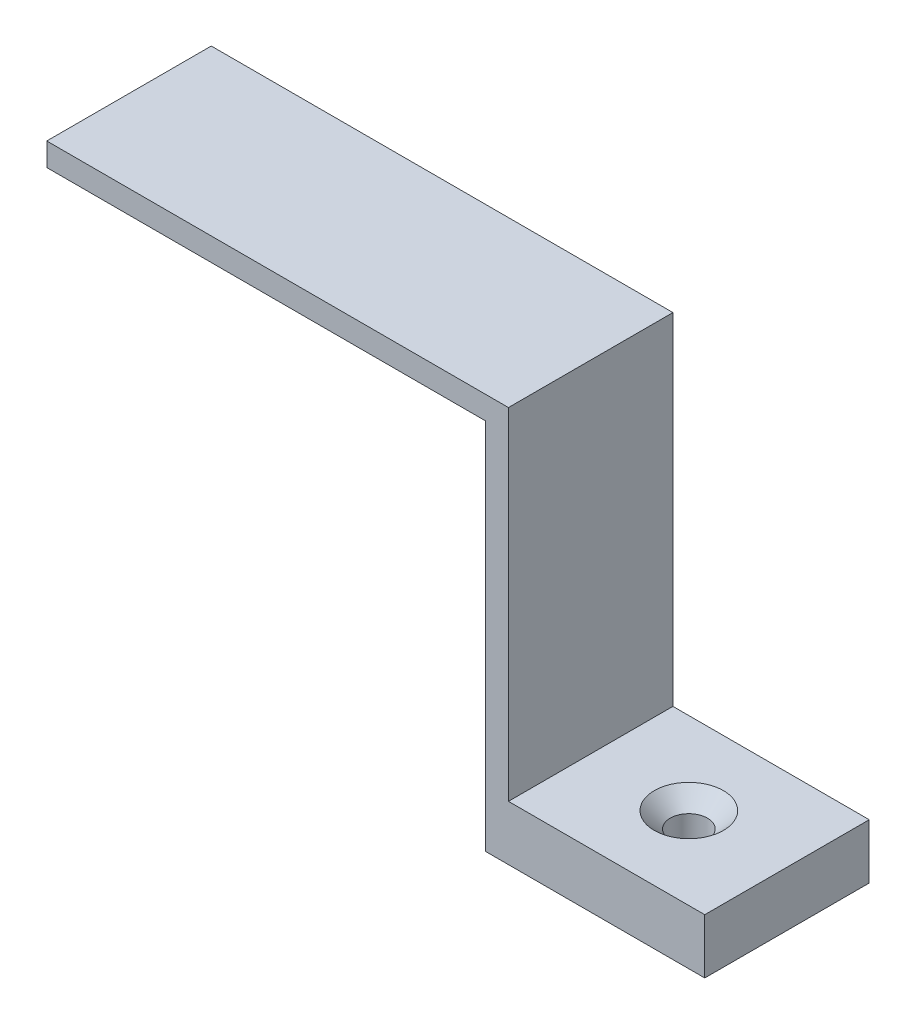
from build123d import *

# Parameters (mm, degrees)
SALIENTE_EXTRUIR1_DEPTH                              = 15
CROQUIS2_R                                           = 1.5
CORTAR_EXTRUIR1_DEPTH                                = 5
AVELLANADO_PARA_TORNILLO_CON_CABEZA_PLAN_D           = 3.4
AVELLANADO_PARA_TORNILLO_CON_CABEZA_PLAN_CSINK_D     = 6.3
AVELLANADO_PARA_TORNILLO_CON_CABEZA_PLAN_CSINK_ANGLE = 90


with BuildPart() as part:
    # Croquis1 → Saliente-Extruir1 (new body)
    with BuildSketch(Plane.XY):
        Polygon((-24.277819577, -18.779195804), (-24.277819577, -23.779195804), (-44.277819577, -23.779195804), (-44.277819577, 10.220804196), (-84.277819577, 10.220804196), (-84.277819577, 12.320804196), (-42.177819577, 12.320804196), (-42.177819577, -18.779195804), align=None)
    extrude(amount=SALIENTE_EXTRUIR1_DEPTH)

    # Croquis2 → Cortar-Extruir1 (cut)
    with BuildSketch(Plane(origin=(0, -18.779195804, 0), x_dir=(1, 0, 0), z_dir=(0, 1, 0))):
        with Locations((-33.227819577, -7.5)):
            Circle(CROQUIS2_R)
    extrude(amount=-CORTAR_EXTRUIR1_DEPTH, mode=Mode.SUBTRACT)

    # Avellanado para tornillo con cabeza plana avellanada de M31 (through all)
    with Locations(Plane(origin=(0, -18.779195804, 0), x_dir=(1, 0, 0), z_dir=(0, 1, 0))):
        with Locations((-33.227819577, -7.5)):
            CounterSinkHole(AVELLANADO_PARA_TORNILLO_CON_CABEZA_PLAN_D / 2, AVELLANADO_PARA_TORNILLO_CON_CABEZA_PLAN_CSINK_D / 2, counter_sink_angle=AVELLANADO_PARA_TORNILLO_CON_CABEZA_PLAN_CSINK_ANGLE)


solid = part.part
